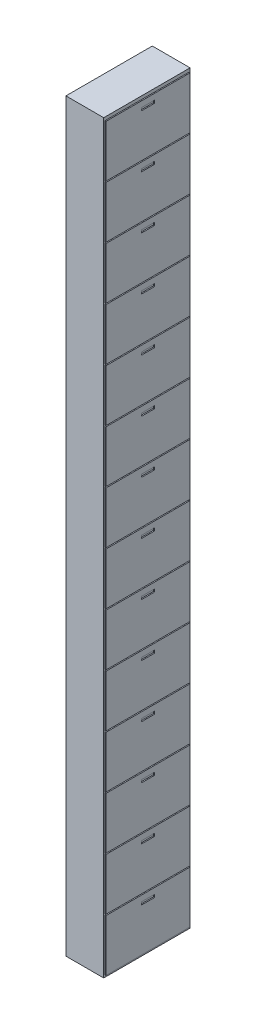
from build123d import *

# Parameters (mm, degrees)
SKETCH1_W           = 350
SKETCH1_H           = 6900
BOSS_EXTRUDE1_DEPTH = 800
SKETCH3_W           = 780
SKETCH3_H           = 480
SKETCH3_W_2         = 121.072841775
SKETCH3_H_2         = 25.802408902
BOSS_EXTRUDE3_DEPTH = 10


with BuildPart() as part:
    # Sketch1 → Boss-Extrude1 (new body)
    with BuildSketch(Plane.XY):
        with Locations((38.061970043, 729.986327315)):
            Rectangle(SKETCH1_W, SKETCH1_H)
    extrude(amount=BOSS_EXTRUDE1_DEPTH)

    # Sketch3 → Boss-Extrude3 (add)
    with BuildSketch(Plane(origin=(213.061970043, 0, 0), x_dir=(0, 0, -1), z_dir=(1, 0, 0))):
        with Locations((-400, -2460.013672685)):
            Rectangle(SKETCH3_W, SKETCH3_H)
        with Locations((-401.128332344, -2287.011976611)):
            Rectangle(SKETCH3_W_2, SKETCH3_H_2, mode=Mode.SUBTRACT)
        with Locations((-400, -1480.013672685)):
            Rectangle(SKETCH3_W, SKETCH3_H)
        with Locations((-401.128332344, -1307.011976611)):
            Rectangle(SKETCH3_W_2, SKETCH3_H_2, mode=Mode.SUBTRACT)
        with Locations((-400, -1970.013672685)):
            Rectangle(SKETCH3_W, SKETCH3_H)
        with Locations((-401.128332344, -1797.011976611)):
            Rectangle(SKETCH3_W_2, SKETCH3_H_2, mode=Mode.SUBTRACT)
        with Locations((-400, -990.013672685)):
            Rectangle(SKETCH3_W, SKETCH3_H)
        with Locations((-401.128332344, -817.011976611)):
            Rectangle(SKETCH3_W_2, SKETCH3_H_2, mode=Mode.SUBTRACT)
        with Locations((-400, -500.013672685)):
            Rectangle(SKETCH3_W, SKETCH3_H)
        with Locations((-401.128332344, -327.011976611)):
            Rectangle(SKETCH3_W_2, SKETCH3_H_2, mode=Mode.SUBTRACT)
        with Locations((-400, -10.013672685)):
            Rectangle(SKETCH3_W, SKETCH3_H)
        with Locations((-401.128332344, 162.988023389)):
            Rectangle(SKETCH3_W_2, SKETCH3_H_2, mode=Mode.SUBTRACT)
        with Locations((-400, 479.986327315)):
            Rectangle(SKETCH3_W, SKETCH3_H)
        with Locations((-401.128332344, 652.988023389)):
            Rectangle(SKETCH3_W_2, SKETCH3_H_2, mode=Mode.SUBTRACT)
        with Locations((-400, 969.986327315)):
            Rectangle(SKETCH3_W, SKETCH3_H)
        with Locations((-401.128332344, 1142.988023389)):
            Rectangle(SKETCH3_W_2, SKETCH3_H_2, mode=Mode.SUBTRACT)
        with Locations((-400, 1459.986327315)):
            Rectangle(SKETCH3_W, SKETCH3_H)
        with Locations((-401.128332344, 1632.988023389)):
            Rectangle(SKETCH3_W_2, SKETCH3_H_2, mode=Mode.SUBTRACT)
        with Locations((-400, 1949.986327315)):
            Rectangle(SKETCH3_W, SKETCH3_H)
        with Locations((-401.128332344, 2122.988023389)):
            Rectangle(SKETCH3_W_2, SKETCH3_H_2, mode=Mode.SUBTRACT)
        with Locations((-400, 2439.986327315)):
            Rectangle(SKETCH3_W, SKETCH3_H)
        with Locations((-401.128332344, 2612.988023389)):
            Rectangle(SKETCH3_W_2, SKETCH3_H_2, mode=Mode.SUBTRACT)
        with Locations((-400, 2929.986327315)):
            Rectangle(SKETCH3_W, SKETCH3_H)
        with Locations((-401.128332344, 3102.988023389)):
            Rectangle(SKETCH3_W_2, SKETCH3_H_2, mode=Mode.SUBTRACT)
        with Locations((-400, 3419.986327315)):
            Rectangle(SKETCH3_W, SKETCH3_H)
        with Locations((-401.128332344, 3592.988023389)):
            Rectangle(SKETCH3_W_2, SKETCH3_H_2, mode=Mode.SUBTRACT)
        with Locations((-400, 3909.986327315)):
            Rectangle(SKETCH3_W, SKETCH3_H)
        with Locations((-401.128332344, 4082.988023389)):
            Rectangle(SKETCH3_W_2, SKETCH3_H_2, mode=Mode.SUBTRACT)
    extrude(amount=BOSS_EXTRUDE3_DEPTH)


solid = part.part
